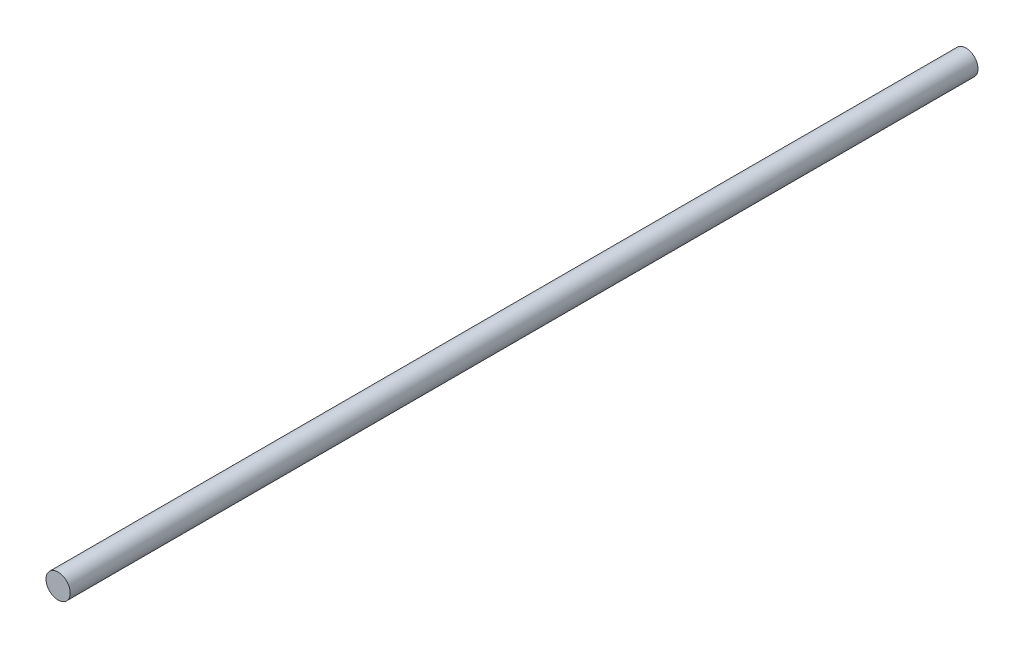
from build123d import *

# Parameters (mm, degrees)
SKETCH2_R           = 4
BOSS_EXTRUDE1_DEPTH = 300


with BuildPart() as part:
    # Sketch2 → Boss-Extrude1 (new body)
    with BuildSketch(Plane.XY):
        Circle(SKETCH2_R)
    extrude(amount=BOSS_EXTRUDE1_DEPTH)


solid = part.part
